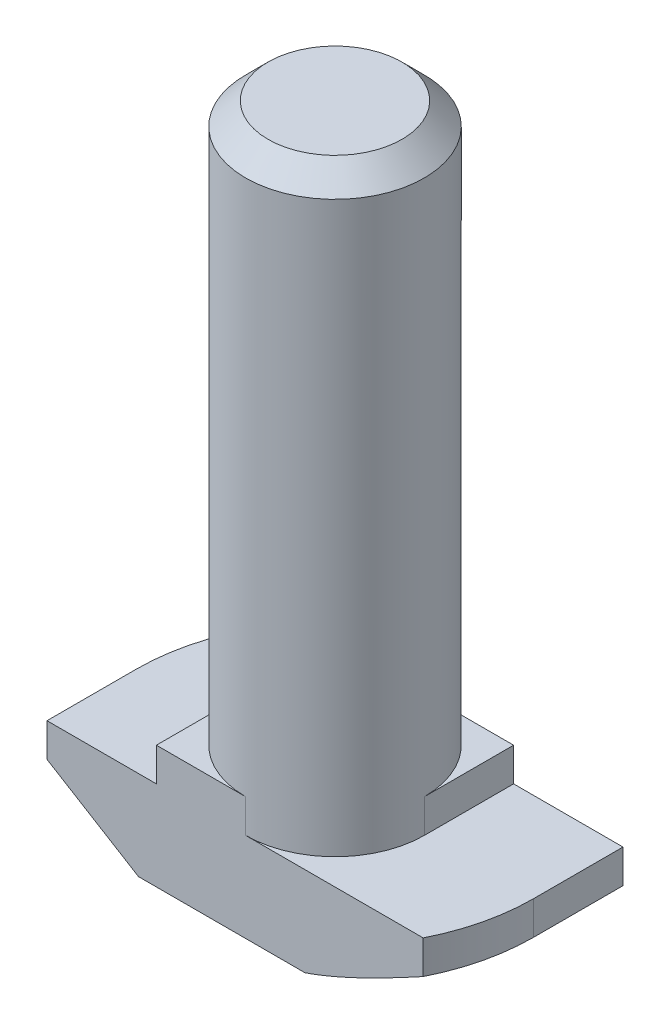
from build123d import *

# Parameters (mm, degrees)
EXTRUDE_1_DEPTH     = 4
CUT_EXTRUDE_1_DEPTH = 1.5
SKETCH_2_R          = 4
EXTRUDE_2_DEPTH     = 25
CUT_EXTRUDE_2_DEPTH = 5
CHAMFER_2_SIZE      = 1


with BuildPart() as part:
    # Эскиз1 → Бобышка-Вытянуть1 (new body, symmetric)
    with BuildSketch(Plane.XY):
        Polygon((8.9, 0), (-8.9, 0), (-8.9, 4), (-4, 4), (-4, 5.5), (4, 5.5), (4, 4), (8.9, 4), align=None)
    extrude(amount=EXTRUDE_1_DEPTH, both=True)

    # Эскиз3 → Вырез-Вытянуть1 (cut)
    with BuildSketch(Plane(origin=(0, 5.5, 0), x_dir=(1, 0, 0), z_dir=(0, 1, 0))):
        with BuildLine():
            Line((-4, 0), (-4, 4))
            Line((-4, 4), (0, 4))
            ThreePointArc((0, 4), (-2.828427125, 2.828427125), (-4, 0))
        make_face()
        with BuildLine():
            Line((0, -4), (4, -4))
            Line((4, -4), (4, 0))
            ThreePointArc((4, 0), (2.828427125, -2.828427125), (0, -4))
        make_face()
    extrude(amount=-CUT_EXTRUDE_1_DEPTH, mode=Mode.SUBTRACT)

    # Эскиз2 → Бобышка-Вытянуть2 (add)
    with BuildSketch(Plane(origin=(0, 5.5, 0), x_dir=(1, 0, 0), z_dir=(0, 1, 0))):
        with Locations(Location((0, 0, 0), (0, 0, 270))):  # turned: the seam where the file's is
            Circle(SKETCH_2_R)
    extrude(amount=EXTRUDE_2_DEPTH)

    # Эскиз4 → Вырез-Вытянуть2 (cut, through all)
    with BuildSketch(Plane(origin=(0, 4, 0), x_dir=(1, 0, 0), z_dir=(0, 1, 0))):
        with BuildLine():
            Line((-7.950471684, 4), (-8.9, 4))
            Line((-8.9, 4), (-8.9, 0))
            ThreePointArc((-8.9, 0), (-8.659364815, 2.055578022), (-7.950471684, 4))
        make_face()
        with BuildLine():
            Line((7.950471684, -4), (8.9, -4))
            Line((8.9, -4), (8.9, 0))
            ThreePointArc((8.9, 0), (8.659364815, -2.055578022), (7.950471684, -4))
        make_face()
    extrude(amount=-CUT_EXTRUDE_2_DEPTH, mode=Mode.SUBTRACT)

    # Вырез-По траектории1: sweep along a path in Эскиз6
    with BuildLine(Plane.XZ) as sweep_1_path:
        Line((0, -8.9), (8.9, -8.9))
        Line((8.9, -8.9), (8.9, 0))
        ThreePointArc((8.9, 0), (6.293250353, 6.293250353), (0, 8.9))
        Line((0, 8.9), (-8.9, 8.9))
        Line((-8.9, 8.9), (-8.9, 0))
        ThreePointArc((-8.9, 0), (-6.293250353, -6.293250353), (0, -8.9))
    # Эскиз5 → Вырез-По траектории1 (sweep, cut)
    with BuildSketch(Plane.XY.offset(4)):
        Polygon((-8.9, 2.5), (-4.8, 0), (-8.9, 0), align=None)
    sweep(path=sweep_1_path.line, transition=Transition.RIGHT, mode=Mode.SUBTRACT)

    # Фаска2
    chamfer_2_edges = [part.edges().sort_by_distance(p)[0] for p in [
        (0, 30.5, -4),
    ]]
    chamfer(chamfer_2_edges, length=CHAMFER_2_SIZE)


solid = part.part
